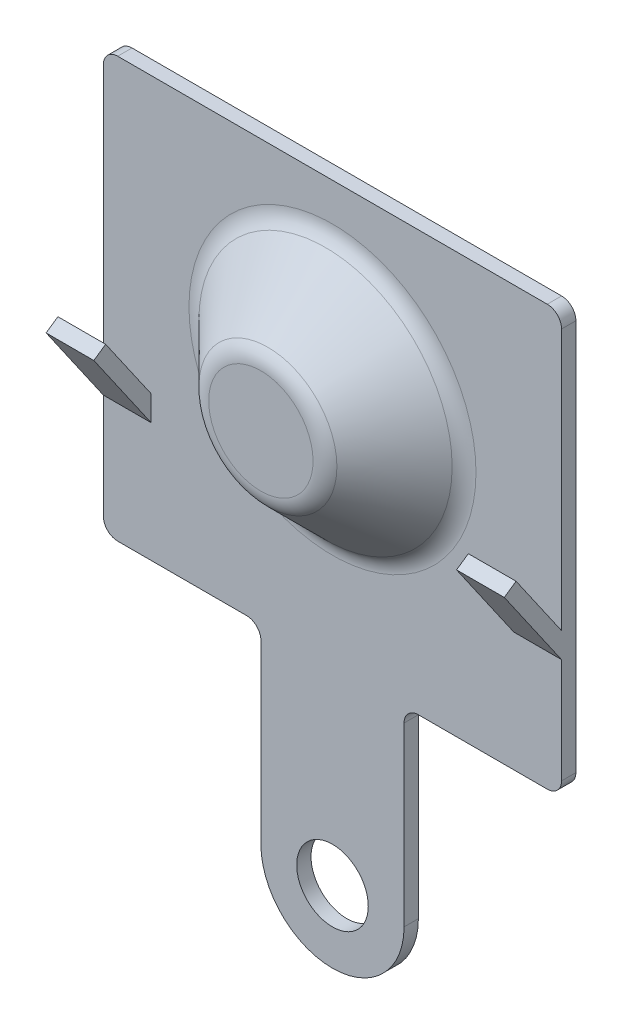
from build123d import *

# Parameters (mm, degrees)
SKETCH1_R           = 0.75
BOSS_EXTRUDE1_DEPTH = 0.3
FILLET1_R           = 0.3
BOSS_EXTRUDE2_DEPTH = 1
FILLET2_R           = 0.5


with BuildPart() as part:
    # Sketch1 → Boss-Extrude1 (new body)
    with BuildSketch(Plane.XY):
        with BuildLine():
            Line((-4.8, 4.4), (4.8, 4.4))
            Line((4.8, 4.4), (4.8, -4.4))
            Line((4.8, -4.4), (1.5, -4.4))
            Line((1.5, -4.4), (1.5, -8.4))
            ThreePointArc((1.5, -8.4), (0, -9.9), (-1.5, -8.4))
            Line((-1.5, -8.4), (-1.5, -4.4))
            Line((-1.5, -4.4), (-4.8, -4.4))
            Line((-4.8, -4.4), (-4.8, 4.4))
        make_face()
        with Locations((0, -8.4)):
            Circle(SKETCH1_R, mode=Mode.SUBTRACT)
    extrude(amount=BOSS_EXTRUDE1_DEPTH)

    # Fillet1
    fillet1_edges = [part.edges().sort_by_distance(p)[0] for p in [
        (-4.8, -4.4, 0.15),
        (-4.8, 4.4, 0.15),
        (4.8, 4.4, 0.15),
        (4.8, -4.4, 0.15),
        (1.5, -4.4, 0.15),
        (-1.5, -4.4, 0.15),
    ]]
    fillet(fillet1_edges, radius=FILLET1_R)

    # Sketch2 → Boss-Extrude2 (add)
    with BuildSketch(Plane(origin=(4.8, 0, 0), x_dir=(0, 0, -1), z_dir=(1, 0, 0))):
        Polygon((-0.3, -1.9), (-1.5, -0.171055671), (-1.253545223, 0), (-0.3, -1.373855504), align=None)
    boss_extrude2 = extrude(amount=-BOSS_EXTRUDE2_DEPTH)

    # Mirror1: Boss-Extrude2 across plane
    add(boss_extrude2.mirror(Plane(origin=(0, 0, 0), x_dir=(0, 0, 1), z_dir=(1, 0, 0))))

    # Sketch3 → Revolve1 (revolve)
    with BuildSketch(Plane(origin=(0, 0, 0), x_dir=(0, 0, -1), z_dir=(1, 0, 0))):
        Polygon((-1.8, 0.6), (-1.8, 1.9), (-0.3, 3.4), (-0.3, 0.6), align=None)
    revolve(axis=Axis((0, 0.6, 0.3), (0, 0, 1)))

    # Fillet2
    fillet2_edges = [part.edges().sort_by_distance(p)[0] for p in [
        (0, -0.7, 1.8),
        (0, -2.2, 0.3),
    ]]
    fillet(fillet2_edges, radius=FILLET2_R)


solid = part.part
